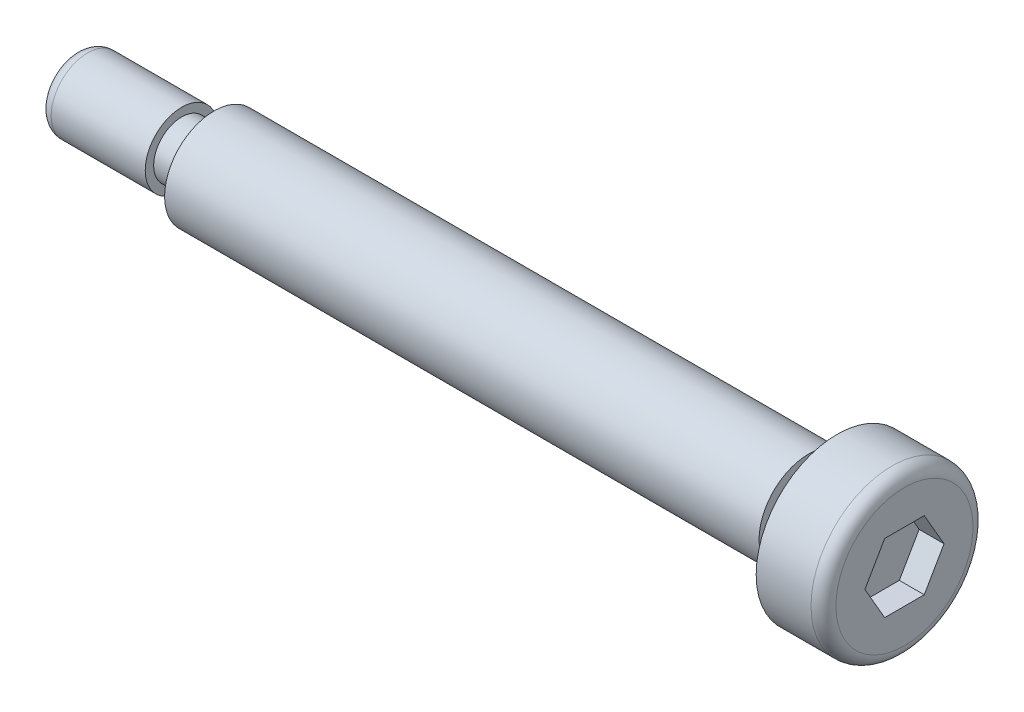
from build123d import *

# Parameters (mm, degrees)
CUT_EXTRUDE1_DEPTH = 2


with BuildPart() as part:
    # Sketch2 → Revolve1 (revolve)
    with BuildSketch(Plane.XY):
        with BuildLine():
            Line((-50, 3.97), (-2.3, 3.97))
            Line((-2.3, 3.97), (-2.3, 3.25))
            Line((-2.3, 3.25), (0, 3.25))
            Line((0, 3.25), (0, 6.5))
            Line((0, 6.5), (4.4, 6.5))
            ThreePointArc((4.4, 6.5), (5.107106781, 6.207106781), (5.4, 5.5))
            Line((5.4, 5.5), (5.4, 0))
            Line((5.4, 0), (-61.15, 0))
            Line((-61.15, 0), (-61.15, 1.925))
            ThreePointArc((-61.15, 1.925), (-60.857106781, 2.632106781), (-60.15, 2.925))
            Line((-60.15, 2.925), (-52.6, 2.925))
            Line((-52.6, 2.925), (-52.6, 2.25))
            Line((-52.6, 2.25), (-50, 2.25))
            Line((-50, 2.25), (-50, 3.97))
        make_face()
    revolve(axis=Axis((-61.15, 0, 0), (1, 0, 0)))

    # Sketch3 → Cut-Extrude1 (cut)
    with BuildSketch(Plane(origin=(5.4, 0, 0), x_dir=(0, 0, -1), z_dir=(1, 0, 0))):
        Polygon((1.58771324, 2.75), (-1.58771324, 2.75), (-3.175426481, 0), (-1.58771324, -2.75), (1.58771324, -2.75), (3.175426481, 0), align=None)
    extrude(amount=-CUT_EXTRUDE1_DEPTH, mode=Mode.SUBTRACT)


solid = part.part
